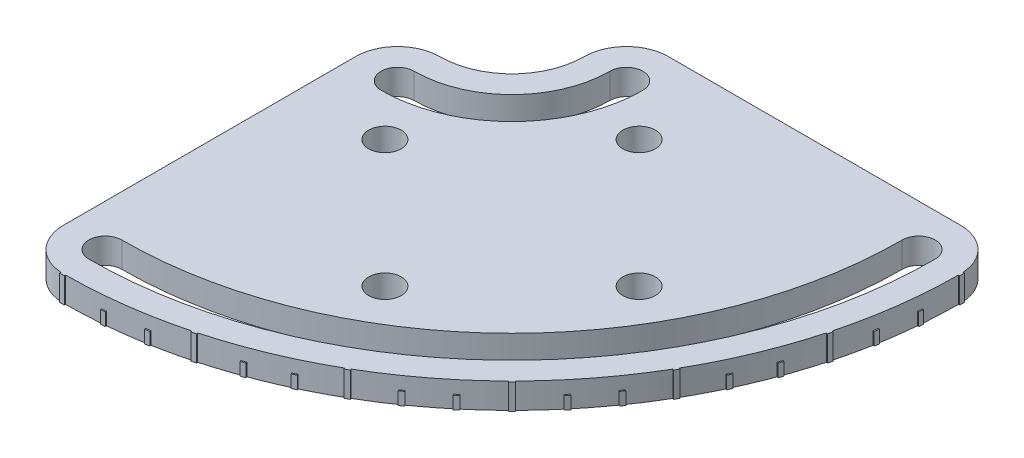
from build123d import *

# Parameters (mm, degrees)
SKETCH_1_R               = 3.2
EXTRUDE_1_DEPTH          = 5
EXTRUDE_2_DEPTH          = 5
PATTERN_CIRCULAR_1_COUNT = 7
PATTERN_CIRCULAR_1_ANGLE = 90
EXTRUDE_3_DEPTH          = 2.5
PATTERN_CIRCULAR_2_COUNT = 19
PATTERN_CIRCULAR_2_ANGLE = 90


with BuildPart() as part:
    # 스케치1 → 보스-돌출1 (new body)
    with BuildSketch(Plane(origin=(0, 0, 0), x_dir=(1, 0, 0), z_dir=(0, 1, 0))):
        with BuildLine():
            Line((-8.25, -80), (-8.25, -22.5))
            ThreePointArc((-8.25, -22.5), (-5.833630945, -16.666369055), (0, -14.25))
            ThreePointArc((0, -14.25), (10.076271632, -10.076271632), (14.25, 0))
            ThreePointArc((14.25, 0), (16.666369055, 5.833630945), (22.5, 8.25))
            Line((22.5, 8.25), (80, 8.25))
            ThreePointArc((80, 8.25), (85.833630945, 5.833630945), (88.25, 0))
            ThreePointArc((88.25, 0), (62.40217344, -62.40217344), (0, -88.25))
            ThreePointArc((0, -88.25), (-5.833630945, -85.833630945), (-8.25, -80))
        make_face()
        with Locations((58.75, -33.75)):
            Circle(SKETCH_1_R, mode=Mode.SUBTRACT)
        with Locations((33.75, -58.75)):
            Circle(SKETCH_1_R, mode=Mode.SUBTRACT)
        with Locations((8.75, -33.75)):
            Circle(SKETCH_1_R, mode=Mode.SUBTRACT)
        with Locations((33.75, -8.75)):
            Circle(SKETCH_1_R, mode=Mode.SUBTRACT)
        with BuildLine():
            ThreePointArc((0, -19.25), (-3.25, -22.5), (0, -25.75))
            ThreePointArc((0, -25.75), (18.207999616, -18.207999616), (25.75, 0))
            ThreePointArc((25.75, 0), (22.5, 3.25), (19.25, 0))
            ThreePointArc((19.25, 0), (13.611805538, -13.611805538), (0, -19.25))
        make_face(mode=Mode.SUBTRACT)
        with BuildLine():
            ThreePointArc((0, -76.75), (-3.25, -80), (0, -83.25))
            ThreePointArc((0, -83.25), (58.866639534, -58.866639534), (83.25, 0))
            ThreePointArc((83.25, 0), (80, 3.25), (76.75, 0))
            ThreePointArc((76.75, 0), (54.270445456, -54.270445456), (0, -76.75))
        make_face(mode=Mode.SUBTRACT)
    extrude(amount=EXTRUDE_1_DEPTH)

    # 스케치2 → 보스-돌출2 (add)
    with BuildSketch(Plane(origin=(0, 5, 0), x_dir=(1, 0, 0), z_dir=(0, 1, 0))):
        with BuildLine():
            Line((0.458146835, -87.498800572), (0.463382799, -88.498786864))
            ThreePointArc((0.463382799, -88.498786864), (0, -88.5), (-0.463382799, -88.498786864))
            Line((-0.463382799, -88.498786864), (-0.458146835, -87.498800572))
            ThreePointArc((-0.458146835, -87.498800572), (0, -87.5), (0.458146835, -87.498800572))
        make_face()
    extrude_2 = extrude(amount=-EXTRUDE_2_DEPTH)

    # 원형 패턴1: 보스-돌출2 ×7 about axis
    pattern_circular_1_axis = Axis((0, 0, 0), (0, 1, 0))
    for i in range(1, PATTERN_CIRCULAR_1_COUNT):
        add(extrude_2.rotate(pattern_circular_1_axis, i * PATTERN_CIRCULAR_1_ANGLE / (PATTERN_CIRCULAR_1_COUNT - 1)))

    # 스케치6 → 보스-돌출3 (add)
    with BuildSketch(Plane.XZ):
        with BuildLine():
            Line((88.498786864, 0.463382799), (87.998793718, 0.460764817))
            ThreePointArc((87.998793718, 0.460764817), (88, 0), (87.998793718, -0.460764817))
            Line((87.998793718, -0.460764817), (88.498786864, -0.463382799))
            ThreePointArc((88.498786864, -0.463382799), (88.5, 0), (88.498786864, 0.463382799))
        make_face()
    extrude_3 = extrude(amount=-EXTRUDE_3_DEPTH)

    # 원형 패턴2: 보스-돌출3 ×19 about axis
    pattern_circular_2_axis = Axis((0, 5, 0), (0, -1, 0))
    for i in range(1, PATTERN_CIRCULAR_2_COUNT):
        add(extrude_3.rotate(pattern_circular_2_axis, i * PATTERN_CIRCULAR_2_ANGLE / (PATTERN_CIRCULAR_2_COUNT - 1)))


solid = part.part
